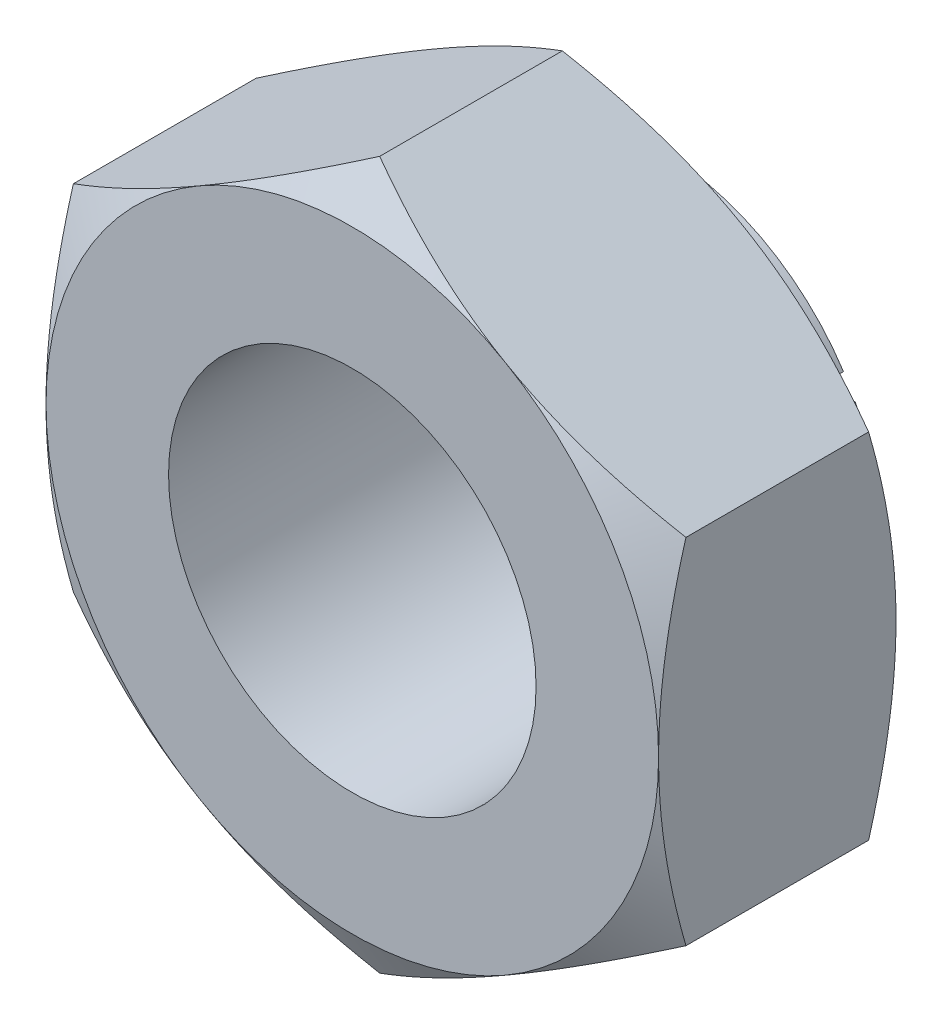
from build123d import *

# Parameters (mm, degrees)
EXTRUDE1_DEPTH          = 5
SKETCH2_OUTSIDE_W       = 36
SKETCH2_OUTSIDE_H       = 37.548
SKETCH2_OUTSIDE_R       = 5
CUT_EXTRUDE1_DEPTH      = 6
CUT_EXTRUDE1_TAPER      = 60
SKETCH4_R               = 3
CUT_EXTRUDE3_DEPTH      = 6
SKETCH12_OUTSIDE_W      = 15.214
SKETCH12_OUTSIDE_H      = 16.762
SKETCH12_OUTSIDE_R      = 3.6
CUT_EXTRUDE10_DEPTH     = 1.125
SKETCH15_W              = 0.381
SKETCH15_H              = 5.773502692
CUT_EXTRUDE_THIN2_DEPTH = 0.617
CIRPATTERN1_COUNT       = 6
SKETCH3_OUTSIDE_W       = 32.102
SKETCH3_OUTSIDE_H       = 33.65
SKETCH3_OUTSIDE_R       = 5
CUT_EXTRUDE2_DEPTH      = 4.875
CUT_EXTRUDE2_TAPER      = 60


with BuildPart() as part:
    # Sketch1 → Extrude1 (new body)
    with BuildSketch(Plane.XY):
        Polygon((0, 5.773502692), (-5, 2.886751346), (-5, -2.886751346), (0, -5.773502692), (5, -2.886751346), (5, 2.886751346), align=None)
    extrude(amount=-EXTRUDE1_DEPTH)

    # Sketch2 outside → Cut-Extrude1 (cut, through all)
    with BuildSketch(Plane.XY):
        Rectangle(SKETCH2_OUTSIDE_W, SKETCH2_OUTSIDE_H)
        Circle(SKETCH2_OUTSIDE_R, mode=Mode.SUBTRACT)
    extrude(amount=-CUT_EXTRUDE1_DEPTH, taper=CUT_EXTRUDE1_TAPER, mode=Mode.SUBTRACT)

    # Sketch4 → Cut-Extrude3 (cut, through all)
    with BuildSketch(Plane.XY):
        Circle(SKETCH4_R)
    extrude(amount=-CUT_EXTRUDE3_DEPTH, mode=Mode.SUBTRACT)

    # Sketch12 outside → Cut-Extrude10 (cut)
    with BuildSketch(Plane(origin=(0, 0, -5), x_dir=(-1, 0, 0), z_dir=(0, 0, -1))):
        Rectangle(SKETCH12_OUTSIDE_W, SKETCH12_OUTSIDE_H)
        Circle(SKETCH12_OUTSIDE_R, mode=Mode.SUBTRACT)
    extrude(amount=-CUT_EXTRUDE10_DEPTH, mode=Mode.SUBTRACT)

    # Sketch15 → Cut-Extrude-Thin2 (cut)
    with BuildSketch(Plane(origin=(0, 0, -5), x_dir=(-1, 0, 0), z_dir=(0, 0, -1))):
        with Locations((0, -2.886751346)):
            Rectangle(SKETCH15_W, SKETCH15_H)
    cut_extrude_thin2 = extrude(amount=-CUT_EXTRUDE_THIN2_DEPTH, mode=Mode.SUBTRACT)

    # CirPattern1: Cut-Extrude-Thin2 ×6 about axis
    cirpattern1_axis = Axis((0, 0, 0), (0, 0, 1))
    for i in range(1, CIRPATTERN1_COUNT):
        add(cut_extrude_thin2.rotate(cirpattern1_axis, i * 360 / CIRPATTERN1_COUNT), mode=Mode.SUBTRACT)

    # Sketch3 outside → Cut-Extrude2 (cut, through all)
    with BuildSketch(Plane(origin=(0, 0, -3.875), x_dir=(-1, 0, 0), z_dir=(0, 0, -1))):
        Rectangle(SKETCH3_OUTSIDE_W, SKETCH3_OUTSIDE_H)
        Circle(SKETCH3_OUTSIDE_R, mode=Mode.SUBTRACT)
    extrude(amount=-CUT_EXTRUDE2_DEPTH, taper=CUT_EXTRUDE2_TAPER, mode=Mode.SUBTRACT)


solid = part.part
